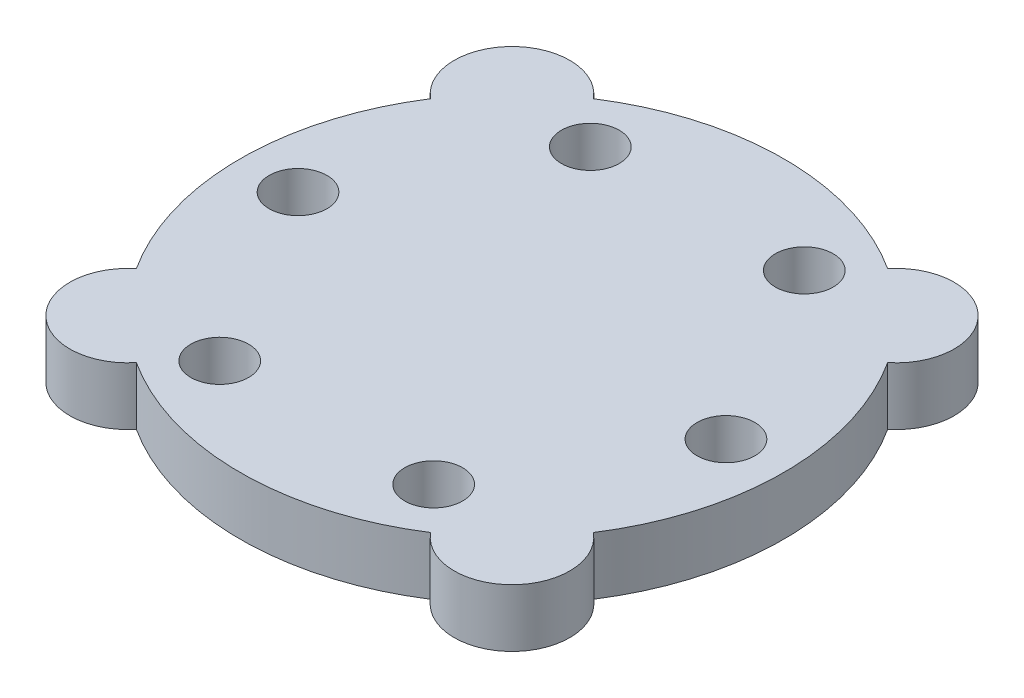
from build123d import *

# Parameters (mm, degrees)
BOSS_EXTRUDE1_DEPTH = 0.25
CUT_EXTRUDE1_REACH  = 2.5
SKETCH2_R           = 0.25


with BuildPart() as part:
    # Sketch1 → Boss-Extrude1 (new body, symmetric)
    with BuildSketch(Plane(origin=(0, 0, 0), x_dir=(1, 0, 0), z_dir=(0, 1, 0))):
        with BuildLine():
            ThreePointArc((-1.975635929, 1.272541817), (-2.35, 0), (-1.975635929, -1.272541817))
            ThreePointArc((-1.975635929, -1.272541817), (-2.015254326, -2.015254326), (-1.272541817, -1.975635929))
            ThreePointArc((-1.272541817, -1.975635929), (0, -2.35), (1.272541817, -1.975635929))
            ThreePointArc((1.272541817, -1.975635929), (2.015254326, -2.015254326), (1.975635929, -1.272541817))
            ThreePointArc((1.975635929, -1.272541817), (2.35, 0), (1.975635929, 1.272541817))
            ThreePointArc((1.975635929, 1.272541817), (2.015254326, 2.015254326), (1.272541817, 1.975635929))
            ThreePointArc((1.272541817, 1.975635929), (0, 2.35), (-1.272541817, 1.975635929))
            ThreePointArc((-1.272541817, 1.975635929), (-2.015254326, 2.015254326), (-1.975635929, 1.272541817))
        make_face()
    extrude(amount=BOSS_EXTRUDE1_DEPTH, both=True)

    # Sketch2 → Cut-Extrude1 (cut, up to next)
    with BuildSketch(Plane(origin=(0, 0.25, 0), x_dir=(1, 0, 0), z_dir=(0, 1, 0)), mode=Mode.PRIVATE) as cut_extrude1_sk1:
        with Locations((-1.85, 0)):
            Circle(SKETCH2_R)
    cut_extrude1_tool1 = extrude(cut_extrude1_sk1.sketch, amount=-CUT_EXTRUDE1_REACH, mode=Mode.PRIVATE) & part.part
    add(cut_extrude1_tool1.solids().sort_by_distance((-1.85, 0.25, 0))[0], mode=Mode.SUBTRACT)
    # Sketch2 → Cut-Extrude1 (cut, up to next)
    with BuildSketch(Plane(origin=(0, 0.25, 0), x_dir=(1, 0, 0), z_dir=(0, 1, 0)), mode=Mode.PRIVATE) as cut_extrude1_sk2:
        with Locations((-0.925, 1.602146997)):
            Circle(SKETCH2_R)
    cut_extrude1_tool2 = extrude(cut_extrude1_sk2.sketch, amount=-CUT_EXTRUDE1_REACH, mode=Mode.PRIVATE) & part.part
    add(cut_extrude1_tool2.solids().sort_by_distance((-0.925, 0.25, -1.602147))[0], mode=Mode.SUBTRACT)
    # Sketch2 → Cut-Extrude1 (cut, up to next)
    with BuildSketch(Plane(origin=(0, 0.25, 0), x_dir=(1, 0, 0), z_dir=(0, 1, 0)), mode=Mode.PRIVATE) as cut_extrude1_sk3:
        with Locations((0.925, 1.602146997)):
            Circle(SKETCH2_R)
    cut_extrude1_tool3 = extrude(cut_extrude1_sk3.sketch, amount=-CUT_EXTRUDE1_REACH, mode=Mode.PRIVATE) & part.part
    add(cut_extrude1_tool3.solids().sort_by_distance((0.925, 0.25, -1.602147))[0], mode=Mode.SUBTRACT)
    # Sketch2 → Cut-Extrude1 (cut, up to next)
    with BuildSketch(Plane(origin=(0, 0.25, 0), x_dir=(1, 0, 0), z_dir=(0, 1, 0)), mode=Mode.PRIVATE) as cut_extrude1_sk4:
        with Locations((1.85, 0)):
            Circle(SKETCH2_R)
    cut_extrude1_tool4 = extrude(cut_extrude1_sk4.sketch, amount=-CUT_EXTRUDE1_REACH, mode=Mode.PRIVATE) & part.part
    add(cut_extrude1_tool4.solids().sort_by_distance((1.85, 0.25, 0))[0], mode=Mode.SUBTRACT)
    # Sketch2 → Cut-Extrude1 (cut, up to next)
    with BuildSketch(Plane(origin=(0, 0.25, 0), x_dir=(1, 0, 0), z_dir=(0, 1, 0)), mode=Mode.PRIVATE) as cut_extrude1_sk5:
        with Locations((0.925, -1.602146997)):
            Circle(SKETCH2_R)
    cut_extrude1_tool5 = extrude(cut_extrude1_sk5.sketch, amount=-CUT_EXTRUDE1_REACH, mode=Mode.PRIVATE) & part.part
    add(cut_extrude1_tool5.solids().sort_by_distance((0.925, 0.25, 1.602147))[0], mode=Mode.SUBTRACT)
    # Sketch2 → Cut-Extrude1 (cut, up to next)
    with BuildSketch(Plane(origin=(0, 0.25, 0), x_dir=(1, 0, 0), z_dir=(0, 1, 0)), mode=Mode.PRIVATE) as cut_extrude1_sk6:
        with Locations((-0.925, -1.602146997)):
            Circle(SKETCH2_R)
    cut_extrude1_tool6 = extrude(cut_extrude1_sk6.sketch, amount=-CUT_EXTRUDE1_REACH, mode=Mode.PRIVATE) & part.part
    add(cut_extrude1_tool6.solids().sort_by_distance((-0.925, 0.25, 1.602147))[0], mode=Mode.SUBTRACT)


solid = part.part
